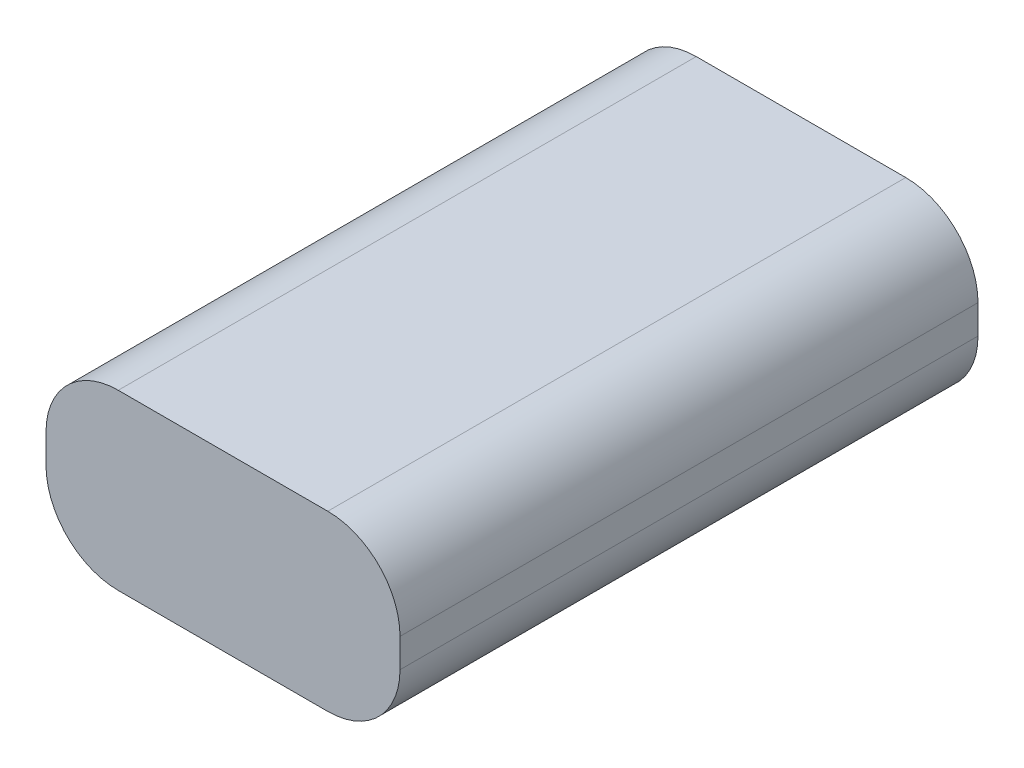
from build123d import *

# Parameters (mm, degrees)
SKIZZE1_W                       = 49
SKIZZE1_H                       = 24
AUFSATZ_LINEAR_AUSTRAGEN1_DEPTH = 80
VERRUNDUNG1_R                   = 10


with BuildPart() as part:
    # Skizze1 → Aufsatz-Linear austragen1 (new body)
    with BuildSketch(Plane.XY):
        with Locations((24.5, 12)):
            Rectangle(SKIZZE1_W, SKIZZE1_H)
    extrude(amount=AUFSATZ_LINEAR_AUSTRAGEN1_DEPTH)

    # Verrundung1
    verrundung1_edges = [part.edges().sort_by_distance(p)[0] for p in [
        (0, 24, 40),
        (49, 24, 40),
        (49, 0, 40),
        (0, 0, 40),
    ]]
    fillet(verrundung1_edges, radius=VERRUNDUNG1_R)


solid = part.part
